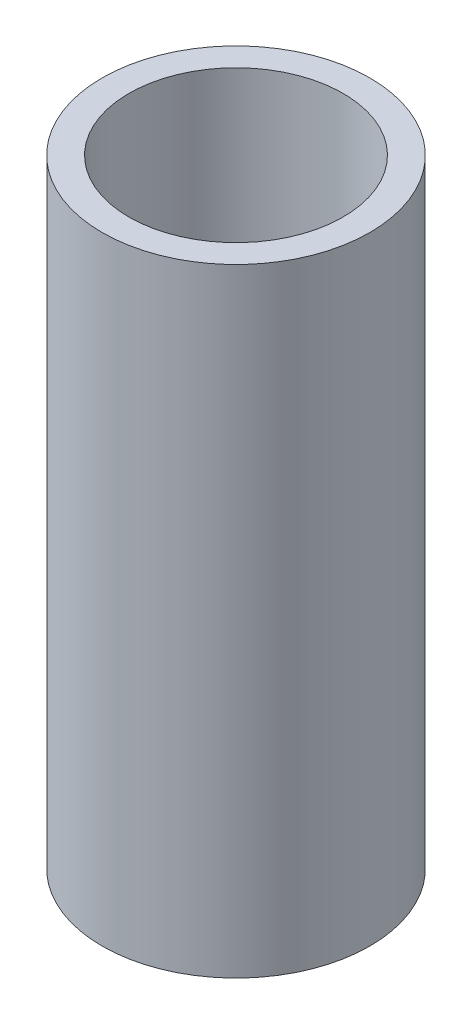
from build123d import *

# Parameters (mm, degrees)
SKETCH2_R           = 3.25
SKETCH2_R_2         = 2.6
BOSS_EXTRUDE1_DEPTH = 15


with BuildPart() as part:
    # Sketch2 → Boss-Extrude1 (new body)
    with BuildSketch(Plane(origin=(0, 0, 0), x_dir=(1, 0, 0), z_dir=(0, 1, 0))):
        Circle(SKETCH2_R)
        Circle(SKETCH2_R_2, mode=Mode.SUBTRACT)
    extrude(amount=BOSS_EXTRUDE1_DEPTH)


solid = part.part
